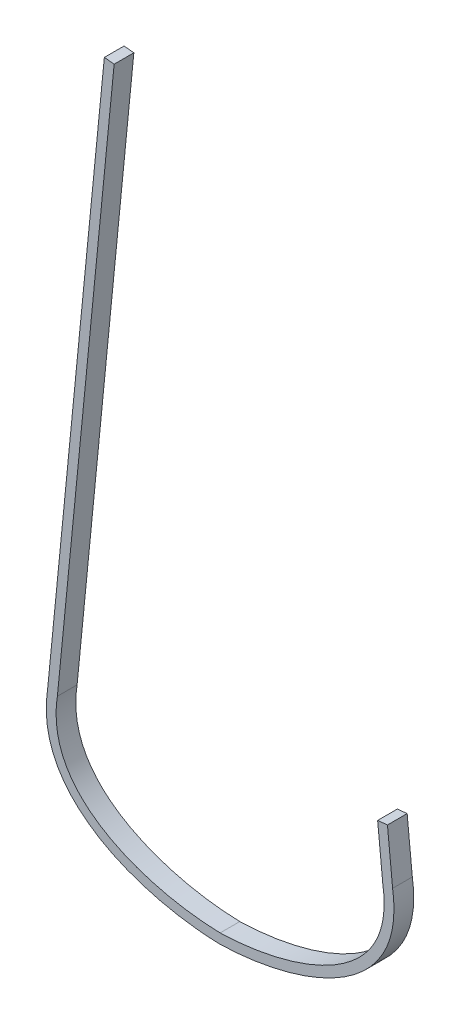
from build123d import *

# Parameters (mm, degrees)
BOSS_EXTRUDE1_DEPTH = 19.05


with BuildPart() as part:
    # Sketch1 → Boss-Extrude1 (new body)
    with BuildSketch(Plane.XY):
        with BuildLine():
            Line((157.234081882, 128.980548454), (152.224173193, 179.795336584))
            Line((152.224173193, 179.795336584), (161.70321507, 180.729890008))
            Line((161.70321507, 180.729890008), (166.6875, 130.175))
            add(Edge.make_bspline(
                [(0, 0), (73.666580622, 1.740675992), (181.188092361, 36.200835609), (166.6875, 130.175)],
                knots=[0, 0, 0, 0, 1, 1, 1, 1], degree=3))
            add(Edge.make_bspline(
                [(0, 0), (-73.666580622, 1.740675992), (-181.188092361, 36.200835609), (-166.6875, 130.175)],
                knots=[0, 0, 0, 0, 1, 1, 1, 1], degree=3))
            Line((-166.6875, 130.175), (-111.860365766, 686.278790089))
            Line((-111.860365766, 686.278790089), (-102.381323889, 685.344236665))
            Line((-102.381323889, 685.344236665), (-157.234081882, 128.980548454))
            add(Edge.make_bspline(
                [(0, 9.52776174), (-1.117611602, 9.555193192), (-3.340472897, 9.624755056), (-7.880039481, 9.827207732), (-13.652210416, 10.198958437), (-20.725459036, 10.840441372), (-30.303235723, 11.962316267), (-42.47749757, 13.875858033), (-57.165232888, 17.02314898), (-71.689613059, 21.050850851), (-90.515854195, 27.626537064), (-112.436111514, 38.157452487), (-130.643933928, 51.803557723), (-142.189146149, 64.564536934), (-149.192253507, 75.075537554), (-153.541361304, 84.674022673), (-156.058613173, 92.923629982), (-157.442658539, 99.418206789), (-158.29640922, 106.242287005), (-158.540175044, 112.221426054), (-158.437150466, 117.190167219), (-158.20642164, 121.010360535), (-157.881730698, 124.277278241), (-157.584058118, 126.601085874), (-157.415798733, 127.781927866), (-157.316566229, 128.446705395), (-157.261207353, 128.804756083), (-157.234081882, 128.980548454)],
                knots=[0.001057036, 0.001057036, 0.001057036, 0.001057036, 0.016679825, 0.032302613, 0.063548191, 0.094793768, 0.126039346, 0.1885305, 0.251021655, 0.31351281, 0.376003965, 0.500986274, 0.625968584, 0.688459739, 0.750950893, 0.813442048, 0.844687626, 0.875933203, 0.90717878, 0.938424358, 0.954047147, 0.969669935, 0.985292724, 0.993104118, 0.997009815, 0.998962664, 1.000915513, 1.000915513, 1.000915513, 1.000915513], degree=3))
            add(Edge.make_bspline(
                [(157.234081882, 128.980548454), (157.261207353, 128.804756083), (157.316566229, 128.446705395), (157.415798733, 127.781927866), (157.584058118, 126.601085874), (157.881730698, 124.277278241), (158.20642164, 121.010360535), (158.437150466, 117.190167219), (158.540175044, 112.221426054), (158.29640922, 106.242287005), (157.442658539, 99.418206789), (156.058613173, 92.923629982), (153.541361304, 84.674022673), (149.192253507, 75.075537554), (142.189146149, 64.564536934), (130.643933928, 51.803557723), (112.436111514, 38.157452487), (90.515854195, 27.626537064), (71.689613059, 21.050850851), (57.165232888, 17.02314898), (42.47749757, 13.875858033), (30.303235723, 11.962316267), (20.725459036, 10.840441372), (13.652210416, 10.198958437), (7.880039481, 9.827207732), (3.340472897, 9.624755056), (1.117611602, 9.555193192), (0, 9.52776174)],
                knots=[0.001057036, 0.001057036, 0.001057036, 0.001057036, 0.003009885, 0.004962733, 0.00886843, 0.016679825, 0.032302613, 0.047925402, 0.063548191, 0.094793768, 0.126039346, 0.157284923, 0.1885305, 0.251021655, 0.31351281, 0.376003965, 0.500986274, 0.625968584, 0.688459739, 0.750950893, 0.813442048, 0.875933203, 0.90717878, 0.938424358, 0.969669935, 0.985292724, 1.000915513, 1.000915513, 1.000915513, 1.000915513], degree=3))
        make_face()
    extrude(amount=BOSS_EXTRUDE1_DEPTH)


solid = part.part
